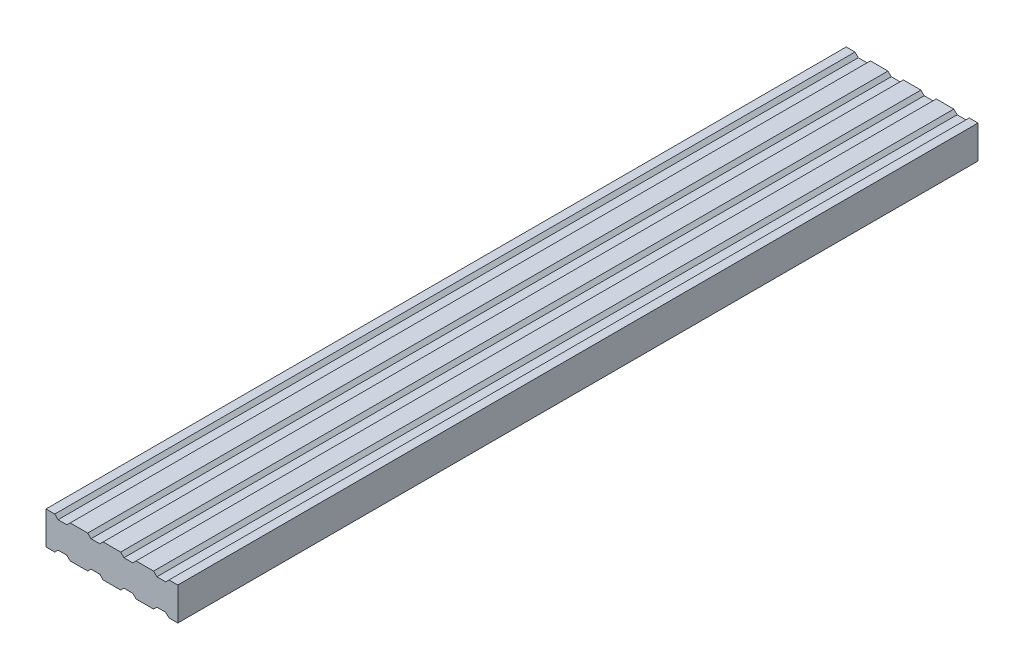
from build123d import *

# Parameters (mm, degrees)
BOSS_EXTRUDE1_DEPTH = 485.87


with BuildPart() as part:
    # Sketch1 → Boss-Extrude1 (new body)
    with BuildSketch(Plane.XY):
        Polygon((34.671573234, -10.000000185), (40.000000001, -10.000000185), (40.000000001, 9.999999821), (34.671573234, 9.999999821), (32.671572877, 7.999999463), (27.328427125, 7.999999463), (25.328426768, 9.999999821), (14.671573234, 9.999999821), (12.671572876, 7.999999463), (7.328427125, 7.999999463), (5.328426767, 9.999999821), (-5.328426766, 9.999999821), (-7.328427124, 7.999999463), (-12.671572876, 7.999999463), (-14.671573233, 9.999999821), (-25.328426767, 9.999999821), (-27.328427124, 7.999999463), (-32.671572876, 7.999999463), (-34.671573233, 9.999999821), (-40, 9.999999821), (-40, -10.000000185), (-34.671573233, -10.000000185), (-32.671572876, -7.999999827), (-27.328427124, -7.999999827), (-25.328426767, -10.000000185), (-14.671573233, -10.000000185), (-12.671572876, -7.999999827), (-7.328427124, -7.999999827), (-5.328426766, -10.000000185), (5.328426767, -10.000000185), (7.328427125, -7.999999827), (12.671572876, -7.999999827), (14.671573234, -10.000000185), (25.328426768, -10.000000185), (27.328427125, -7.999999827), (32.671572877, -7.999999827), align=None)
    extrude(amount=BOSS_EXTRUDE1_DEPTH)


solid = part.part
